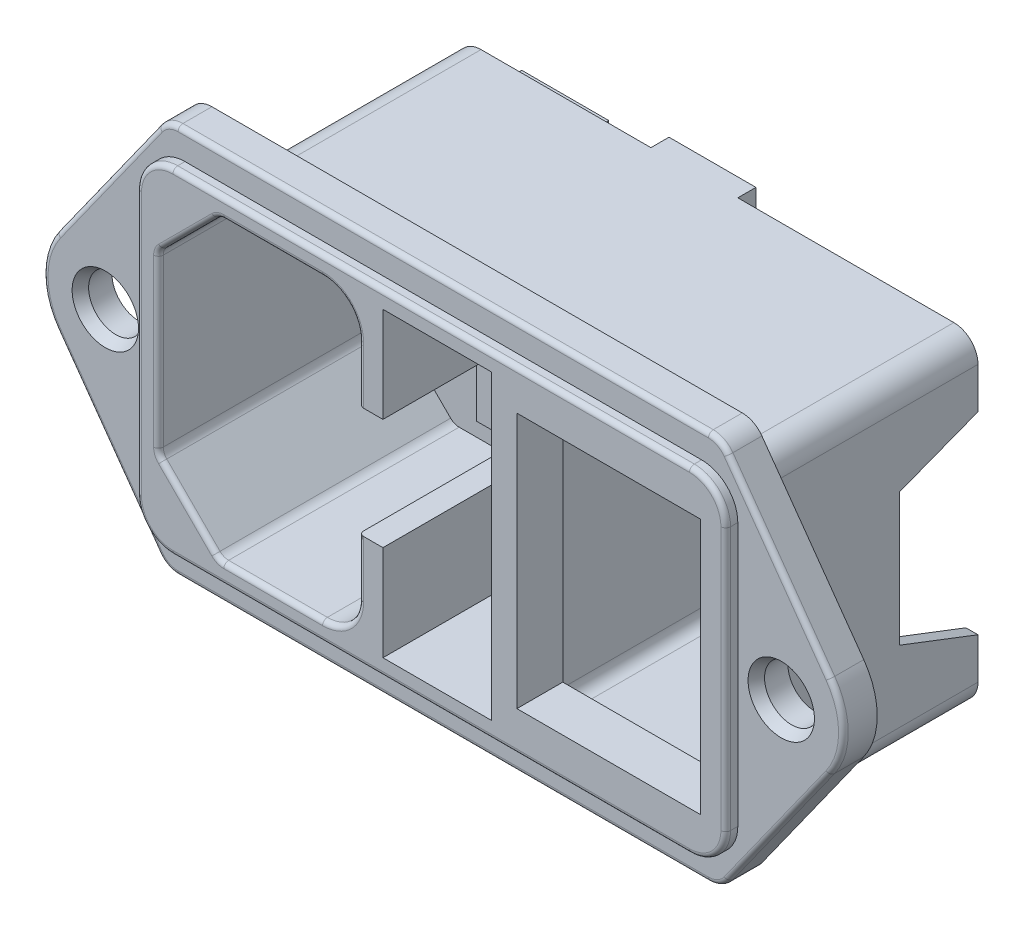
from build123d import *

# Parameters (mm, degrees)
EXTRUDE_513_DEPTH          = 2.8
EXTRUDE_883_DEPTH          = 1
EXTRUDE_1289_DEPTH         = 18
CUT_EXTRUDE_1860_DEPTH     = 19.5
CUT_EXTRUDE_START          = -18
CUT_EXTRUDE_2262_DEPTH     = 18
CUT_EXTRUDE_2475_REACH     = 58.65
CUT_EXTRUDE_2919_REACH     = 23.8
SKETCH_7_W                 = 15.2
SKETCH_7_H                 = 21.2
SKETCH_8_W                 = 5.5
SKETCH_8_H                 = 5.5
SKETCH_8_W_2               = 2
SKETCH_8_H_2               = 2
EXTRUDE_4_DEPTH            = 1.4
CUT_EXTRUDE_5_REACH        = 4.3
SKETCH_8_2_W               = 2
SKETCH_8_2_H               = 2
HOLE_WIZARD_M41_AT_2_COUNT = 2
HOLE_WIZARD_M41_AT_2_PITCH = 56
EXTRUDE_6_DEPTH            = 1.5
EXTRUDE_7_DEPTH            = 1.5
FILLET_2_R                 = 0.8
FILLET_2_OF_MIRROR_2_R     = 0.8
EXTRUDE_8_DEPTH            = 1
CUT_EXTRUDE_6_REACH        = 6.8
SKETCH_14_R                = 2.5
SKETCH_14_W                = 2
SKETCH_14_H                = 2
FILLET_3_R                 = 0.4


with BuildPart() as part:
    # Эскиз1 → Extrude 513 (new body)
    with BuildSketch(Plane.XY):
        with BuildLine():
            Line((-23.598164863, -15.311429633), (-32.034642347, -3.4842889))
            ThreePointArc((-32.034642347, -3.4842889), (-33.15, 0), (-32.034642347, 3.4842889))
            Line((-32.034642347, 3.4842889), (-23.598164863, 15.311429633))
            ThreePointArc((-23.598164863, 15.311429633), (-22.885685625, 15.928040954), (-21.969950747, 16.15))
            Line((-21.969950747, 16.15), (21.969950747, 16.15))
            ThreePointArc((21.969950747, 16.15), (22.885685625, 15.928040954), (23.598164863, 15.311429633))
            Line((23.598164863, 15.311429633), (32.034642347, 3.4842889))
            ThreePointArc((32.034642347, 3.4842889), (33.15, 0), (32.034642347, -3.4842889))
            Line((32.034642347, -3.4842889), (23.598164863, -15.311429633))
            ThreePointArc((23.598164863, -15.311429633), (22.885685625, -15.928040954), (21.969950747, -16.15))
            Line((21.969950747, -16.15), (-21.969950747, -16.15))
            ThreePointArc((-21.969950747, -16.15), (-22.885685625, -15.928040954), (-23.598164863, -15.311429633))
        make_face()
    extrude(amount=EXTRUDE_513_DEPTH)

    # Эскиз2 → Extrude 883 (add)
    with BuildSketch(Plane.XY.offset(2.8)):
        with BuildLine():
            Line((-21.4, -13.9), (21.4, -13.9))
            ThreePointArc((21.4, -13.9), (23.521320344, -13.021320344), (24.4, -10.9))
            Line((24.4, -10.9), (24.4, 10.9))
            ThreePointArc((24.4, 10.9), (23.521320344, 13.021320344), (21.4, 13.9))
            Line((21.4, 13.9), (-21.4, 13.9))
            ThreePointArc((-21.4, 13.9), (-23.521320344, 13.021320344), (-24.4, 10.9))
            Line((-24.4, 10.9), (-24.4, -10.9))
            ThreePointArc((-24.4, -10.9), (-23.521320344, -13.021320344), (-21.4, -13.9))
        make_face()
    extrude(amount=EXTRUDE_883_DEPTH)

    # Эскиз4 → Extrude 1289 (add)
    with BuildSketch(Plane(origin=(0, 0, 0), x_dir=(-1, 0, 0), z_dir=(0, 0, -1))):
        with BuildLine():
            Line((19.085786438, 12.814213562), (22.914213562, 8.985786438))
            ThreePointArc((22.914213562, 8.985786438), (23.347759065, 8.33693974), (23.5, 7.571572875))
            Line((23.5, 7.571572875), (23.5, -7.571572875))
            ThreePointArc((23.5, -7.571572875), (23.347759065, -8.33693974), (22.914213562, -8.985786438))
            Line((22.914213562, -8.985786438), (19.085786438, -12.814213562))
            ThreePointArc((19.085786438, -12.814213562), (18.43693974, -13.247759065), (17.671572875, -13.4))
            Line((17.671572875, -13.4), (-21.5, -13.4))
            ThreePointArc((-21.5, -13.4), (-22.914213562, -12.814213562), (-23.5, -11.4))
            Line((-23.5, -11.4), (-23.5, 11.4))
            ThreePointArc((-23.5, 11.4), (-22.914213562, 12.814213562), (-21.5, 13.4))
            Line((-21.5, 13.4), (17.671572875, 13.4))
            ThreePointArc((17.671572875, 13.4), (18.43693974, 13.247759065), (19.085786438, 12.814213562))
        make_face()
    extrude(amount=EXTRUDE_1289_DEPTH)

    # Эскиз3 → Cut-Extrude 1860 (cut)
    with BuildSketch(Plane.XY.offset(3.8)):
        with BuildLine():
            Line((-17.185786438, -12.3), (-9, -12.3))
            ThreePointArc((-9, -12.3), (-6.878679656, -11.421320344), (-6, -9.3))
            Line((-6, -9.3), (-6, -4.6))
            Line((-6, -4.6), (-4, -4.6))
            Line((-4, -4.6), (-4, -12.5))
            Line((-4, -12.5), (5, -12.5))
            Line((5, -12.5), (5, 12.5))
            Line((5, 12.5), (-4, 12.5))
            Line((-4, 12.5), (-4, 4.6))
            Line((-4, 4.6), (-6, 4.6))
            Line((-6, 4.6), (-6, 9.3))
            ThreePointArc((-6, 9.3), (-6.878679656, 11.421320344), (-9, 12.3))
            Line((-9, 12.3), (-17.185786438, 12.3))
            ThreePointArc((-17.185786438, 12.3), (-17.56846987, 12.223879533), (-17.892893219, 12.007106781))
            Line((-17.892893219, 12.007106781), (-22.307106781, 7.592893219))
            ThreePointArc((-22.307106781, 7.592893219), (-22.523879533, 7.26846987), (-22.6, 6.885786438))
            Line((-22.6, 6.885786438), (-22.6, -6.885786438))
            ThreePointArc((-22.6, -6.885786438), (-22.523879533, -7.26846987), (-22.307106781, -7.592893219))
            Line((-22.307106781, -7.592893219), (-17.892893219, -12.007106781))
            ThreePointArc((-17.892893219, -12.007106781), (-17.56846987, -12.223879533), (-17.185786438, -12.3))
        make_face()
    extrude(amount=-CUT_EXTRUDE_1860_DEPTH, mode=Mode.SUBTRACT)

    # Эскиз5 → Cut-Extrude 2262 (cut)
    with BuildSketch(Plane(origin=(0, 0, -18), x_dir=(-1, 0, 0), z_dir=(0, 0, -1)).offset(CUT_EXTRUDE_START)):
        with BuildLine():
            Line((-21.5, -12.2), (-7.9, -12.2))
            ThreePointArc((-7.9, -12.2), (-7.192893219, -11.907106781), (-6.9, -11.2))
            Line((-6.9, -11.2), (-6.9, 11.2))
            ThreePointArc((-6.9, 11.2), (-7.192893219, 11.907106781), (-7.9, 12.2))
            Line((-7.9, 12.2), (-21.5, 12.2))
            ThreePointArc((-21.5, 12.2), (-22.207106781, 11.907106781), (-22.5, 11.2))
            Line((-22.5, 11.2), (-22.5, -11.2))
            ThreePointArc((-22.5, -11.2), (-22.207106781, -11.907106781), (-21.5, -12.2))
        make_face()
    extrude(amount=CUT_EXTRUDE_2262_DEPTH, mode=Mode.SUBTRACT)

    # Эскиз6 → Cut-Extrude 2475 (cut, up to next)
    with BuildSketch(Plane(origin=(23.5, 0, 0), x_dir=(0, 0, -1), z_dir=(1, 0, 0)), mode=Mode.PRIVATE) as cut_extrude_2475_sk1:
        Polygon((18, -8), (11.5, -5.5), (11.5, 5.5), (18, 8), align=None)
    cut_extrude_2475_tool1 = extrude(cut_extrude_2475_sk1.sketch, amount=-CUT_EXTRUDE_2475_REACH, mode=Mode.PRIVATE) & part.part
    add(cut_extrude_2475_tool1.solids().sort_by_distance((23.5, 0, -14.950617))[0], mode=Mode.SUBTRACT)

    # Эскиз7 → Cut-Extrude 2919 (cut, up to next)
    with BuildSketch(Plane.XY.offset(3.8), mode=Mode.PRIVATE) as cut_extrude_2919_sk1:
        with Locations((14.7, 0)):
            Rectangle(SKETCH_7_W, SKETCH_7_H)
    cut_extrude_2919_tool1 = extrude(cut_extrude_2919_sk1.sketch, amount=-CUT_EXTRUDE_2919_REACH, mode=Mode.PRIVATE) & part.part
    add(cut_extrude_2919_tool1.solids().sort_by_distance((14.7, 0, 3.8))[0], mode=Mode.SUBTRACT)

    # Эскиз8 → Бобышка-Вытянуть4 (add)
    with BuildSketch(Plane.XY.offset(-15.7)):
        with Locations((-11.6, 7)):
            Rectangle(SKETCH_8_W, SKETCH_8_H)
        with Locations((-11.6, 7)):
            Rectangle(SKETCH_8_W_2, SKETCH_8_H_2, mode=Mode.SUBTRACT)
        with Locations((-15.6, 0)):
            Rectangle(SKETCH_8_W, SKETCH_8_H)
        with Locations((-15.6, 0)):
            Rectangle(SKETCH_8_W_2, SKETCH_8_H_2, mode=Mode.SUBTRACT)
        with Locations((-11.6, -7)):
            Rectangle(SKETCH_8_W, SKETCH_8_H)
        with Locations((-11.6, -7)):
            Rectangle(SKETCH_8_W_2, SKETCH_8_H_2, mode=Mode.SUBTRACT)
    extrude(amount=EXTRUDE_4_DEPTH)

    # Эскиз8<2> → Вырез-Вытянуть5 (cut, up to next)
    with BuildSketch(Plane.XY.offset(-15.7), mode=Mode.PRIVATE) as cut_extrude_5_sk1:
        with Locations((-11.6, 7)):
            Rectangle(SKETCH_8_2_W, SKETCH_8_2_H)
    cut_extrude_5_tool1 = extrude(cut_extrude_5_sk1.sketch, amount=-CUT_EXTRUDE_5_REACH, mode=Mode.PRIVATE) & part.part
    add(cut_extrude_5_tool1.solids().sort_by_distance((-11.6, 7, -15.7))[0], mode=Mode.SUBTRACT)
    # Эскиз8<2> → Вырез-Вытянуть5 (cut, up to next)
    with BuildSketch(Plane.XY.offset(-15.7), mode=Mode.PRIVATE) as cut_extrude_5_sk2:
        with Locations((-15.6, 0)):
            Rectangle(SKETCH_8_2_W, SKETCH_8_2_H)
    cut_extrude_5_tool2 = extrude(cut_extrude_5_sk2.sketch, amount=-CUT_EXTRUDE_5_REACH, mode=Mode.PRIVATE) & part.part
    add(cut_extrude_5_tool2.solids().sort_by_distance((-15.6, 0, -15.7))[0], mode=Mode.SUBTRACT)
    # Эскиз8<2> → Вырез-Вытянуть5 (cut, up to next)
    with BuildSketch(Plane.XY.offset(-15.7), mode=Mode.PRIVATE) as cut_extrude_5_sk3:
        with Locations((-11.6, -7)):
            Rectangle(SKETCH_8_2_W, SKETCH_8_2_H)
    cut_extrude_5_tool3 = extrude(cut_extrude_5_sk3.sketch, amount=-CUT_EXTRUDE_5_REACH, mode=Mode.PRIVATE) & part.part
    add(cut_extrude_5_tool3.solids().sort_by_distance((-11.6, -7, -15.7))[0], mode=Mode.SUBTRACT)

    # Эскиз11 → Зенковка для винта с полупотайной головкой M41 (revolve, cut)
    with BuildSketch(Plane(origin=(-28, 0, 2.8), x_dir=(0, -1, 0), z_dir=(1, 0, 0))):
        Polygon((0, 0), (0, 2.8), (2.25, 2.8), (2.25, 0.866025404), (2.75, 0), align=None)
    hole_wizard_m41 = revolve(axis=Axis((-28, 0, 9.15), (0, 0, -1)), mode=Mode.SUBTRACT)

    # Зенковка для винта с полупотайной головкой M41 at 2: Зенковка для винта с полупотайной головкой M41 ×2
    with Locations(*[(i * HOLE_WIZARD_M41_AT_2_PITCH, 0, 0) for i in range(1, HOLE_WIZARD_M41_AT_2_COUNT)]):
        add(hole_wizard_m41, mode=Mode.SUBTRACT)

    # Эскиз13 → Бобышка-Вытянуть6 (add)
    with BuildSketch(Plane(origin=(0, 0, -18), x_dir=(-1, 0, 0), z_dir=(0, 0, -1))):
        Polygon((8.6, 10.3), (12.8, 10.3), (14.4, 8.7), (14.4, 5.3), (12.8, 3.7), (8.6, 3.7), (8.6, 1.9), (11.4, 1.9), (11.4, 0), (12.8, 0), (12.8, 1.7), (14.4, 3.3), (18.6, 3.3), (18.6, 5.1), (15.8, 5.1), (15.8, 12.1), (8.6, 12.1), align=None)
    extrude_6 = extrude(amount=EXTRUDE_6_DEPTH)

    # Эскиз15 → Бобышка-Вытянуть7 (add)
    with BuildSketch(Plane(origin=(0, 0, -18), x_dir=(-1, 0, 0), z_dir=(0, 0, -1))):
        Polygon((-3.6, 2.9), (3.6, 2.9), (3.6, 13.4), (-3.6, 13.4), (-3.6, 11.4), (0.7, 11.4), (2.2, 9.9), (2.2, 6.4), (0.7, 4.9), (-3.6, 4.9), align=None)
    extrude(amount=EXTRUDE_7_DEPTH)

    # Скругление2
    fillet_2_edges = [part.edges().sort_by_distance(p)[0] for p in [
        (-8.6, 3.7, -18.75),
        (-8.6, 1.9, -18.75),
        (-18.6, 3.3, -18.75),
        (-18.6, 5.1, -18.75),
    ]]
    fillet(fillet_2_edges, radius=FILLET_2_R)

    # Зеркальное отражение2: Бобышка-Вытянуть6 across plane
    add(extrude_6.mirror(Plane.ZX))

    # Скругление2 of Зеркальное отражение2
    fillet_2_of_mirror_2_edges = [part.edges().sort_by_distance(p)[0] for p in [
        (-8.6, -3.7, -18.75),
        (-8.6, -1.9, -18.75),
        (-18.6, -3.3, -18.75),
        (-18.6, -5.1, -18.75),
    ]]
    fillet(fillet_2_of_mirror_2_edges, radius=FILLET_2_OF_MIRROR_2_R)

    # Эскиз16 → Бобышка-Вытянуть8 (add)
    with BuildSketch(Plane(origin=(0, 0, -19.5), x_dir=(-1, 0, 0), z_dir=(0, 0, -1))):
        Polygon((14.4, 7), (15.8, 7), (15.8, 3.3), (14.4, 3.3), (12.8, 1.7), (12.8, -1.7), (14.4, -3.3), (15.8, -3.3), (15.8, -7), (14.4, -7), (14.4, -5.3), (12.8, -3.7), (11.4, -3.7), (11.4, -1.9), (11.4, 1.9), (11.4, 3.7), (12.8, 3.7), (14.4, 5.3), align=None)
    extrude(amount=EXTRUDE_8_DEPTH)

    # Эскиз14 → Вырез-Вытянуть6 (cut, up to next)
    with BuildSketch(Plane.XY.offset(-15.7), mode=Mode.PRIVATE) as cut_extrude_6_sk1:
        with Locations((0.5, 0)):
            Circle(SKETCH_14_R)
    cut_extrude_6_tool1 = extrude(cut_extrude_6_sk1.sketch, amount=-CUT_EXTRUDE_6_REACH, mode=Mode.PRIVATE) & part.part
    add(cut_extrude_6_tool1.solids().sort_by_distance((0.5, 0, -15.7))[0], mode=Mode.SUBTRACT)
    # Эскиз14 → Вырез-Вытянуть6 (cut, up to next)
    with BuildSketch(Plane.XY.offset(-15.7), mode=Mode.PRIVATE) as cut_extrude_6_sk2:
        with Locations((0.5, 8)):
            Rectangle(SKETCH_14_W, SKETCH_14_H)
    cut_extrude_6_tool2 = extrude(cut_extrude_6_sk2.sketch, amount=-CUT_EXTRUDE_6_REACH, mode=Mode.PRIVATE) & part.part
    add(cut_extrude_6_tool2.solids().sort_by_distance((0.5, 8, -15.7))[0], mode=Mode.SUBTRACT)
    # Эскиз14 → Вырез-Вытянуть6 (cut, up to next)
    with BuildSketch(Plane.XY.offset(-15.7), mode=Mode.PRIVATE) as cut_extrude_6_sk3:
        with Locations((0.5, -8)):
            Rectangle(SKETCH_14_W, SKETCH_14_H)
    cut_extrude_6_tool3 = extrude(cut_extrude_6_sk3.sketch, amount=-CUT_EXTRUDE_6_REACH, mode=Mode.PRIVATE) & part.part
    add(cut_extrude_6_tool3.solids().sort_by_distance((0.5, -8, -15.7))[0], mode=Mode.SUBTRACT)

    # Скругление3
    fillet_3_edges = [part.edges().sort_by_distance(p)[0] for p in [
        (-6.878679656, -11.421320344, 3.8),
        (-6, -6.95, 3.8),
        (-6, 6.95, 3.8),
        (-6.878679656, 11.421320344, 3.8),
        (-13.092893219, 12.3, 3.8),
        (-17.56846987, 12.223879533, 3.8),
        (-20.1, 9.8, 3.8),
        (-22.523879533, 7.26846987, 3.8),
        (-22.6, 0, 3.8),
        (-22.523879533, -7.26846987, 3.8),
        (-20.1, -9.8, 3.8),
        (-17.56846987, -12.223879533, 3.8),
        (-13.092893219, -12.3, 3.8),
        (-22.885685625, -15.928040954, 2.8),
        (0, -16.15, 2.8),
        (22.885685625, -15.928040954, 2.8),
        (27.816403605, -9.397859267, 2.8),
        (33.15, 0, 2.8),
        (27.816403605, 9.397859267, 2.8),
        (22.885685625, 15.928040954, 2.8),
        (23.521320344, 13.021320344, 3.8),
        (0, 13.9, 3.8),
        (0, 16.15, 2.8),
        (-23.521320344, 13.021320344, 3.8),
        (-24.4, 0, 3.8),
        (-23.521320344, -13.021320344, 3.8),
        (0, -13.9, 3.8),
        (23.521320344, -13.021320344, 3.8),
        (24.4, 0, 3.8),
        (-22.885685625, 15.928040954, 2.8),
        (-27.816403605, 9.397859267, 2.8),
        (-33.15, 0, 2.8),
        (-27.816403605, -9.397859267, 2.8),
    ]]
    fillet(fillet_3_edges, radius=FILLET_3_R)


solid = part.part
